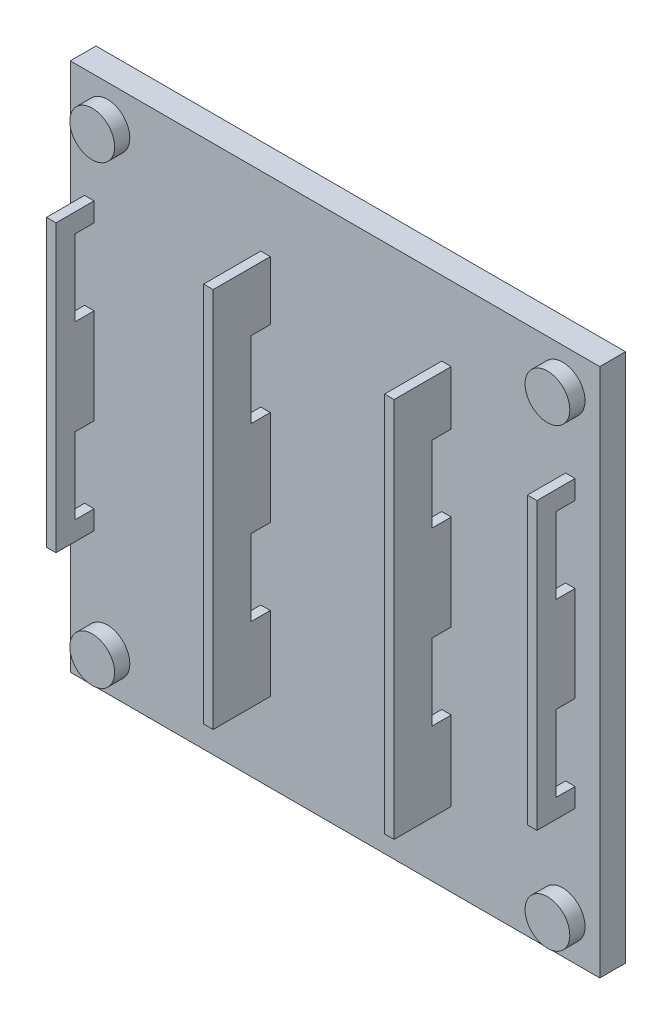
from build123d import *

# Parameters (mm, degrees)
SKICA1_W                 = 55.6
SKICA1_H                 = 55.6
SKICA1_R                 = 2.4
P_IDAT_VYSUNUT_M1_DEPTH  = 1.9
SKICA2_W                 = 55.6
SKICA2_H                 = 55.6
P_IDAT_VYSUNUT_M2_DEPTH  = 0.8
SKICA3_R                 = 2.35
P_IDAT_VYSUNUT_M3_DEPTH  = 1.6
SKICA12_W                = 1
SKICA12_H                = 40
P_IDAT_VYSUNUT_M5_DEPTH  = 6
SKICA13_W                = 1
SKICA13_H                = 30
P_IDAT_VYSUNUT_M6_DEPTH  = 4
SKICA14_W                = 2
SKICA14_H                = 8
ODEBRAT_VYSUNUT_M6_DEPTH = 54
SKICA17_W                = 5.5
SKICA17_H                = 42
SKICA17_W_2              = 42
SKICA17_H_2              = 5.5
ODEBRAT_VYSUNUT_M7_DEPTH = 1.9


with BuildPart() as part:
    # Skica1 → Přidat vysunutím1 (new body)
    with BuildSketch(Plane.XY):
        Rectangle(SKICA1_W, SKICA1_H)
        with Locations((-23.9, 23.9)):
            Circle(SKICA1_R, mode=Mode.SUBTRACT)
        with Locations((23.9, 23.9)):
            Circle(SKICA1_R, mode=Mode.SUBTRACT)
        with Locations((-23.9, -23.9)):
            Circle(SKICA1_R, mode=Mode.SUBTRACT)
        with Locations((23.9, -23.9)):
            Circle(SKICA1_R, mode=Mode.SUBTRACT)
    extrude(amount=P_IDAT_VYSUNUT_M1_DEPTH)

    # Skica2 → Přidat vysunutím2 (add)
    with BuildSketch(Plane.XY.offset(1.9)):
        Rectangle(SKICA2_W, SKICA2_H)
    extrude(amount=P_IDAT_VYSUNUT_M2_DEPTH)

    # Skica3 → Přidat vysunutím3 (add)
    with BuildSketch(Plane.XY.offset(2.7)):
        with Locations((-23.9, 23.9)):
            Circle(SKICA3_R)
        with Locations((23.9, 23.9)):
            Circle(SKICA3_R)
        with Locations((-23.9, -23.9)):
            Circle(SKICA3_R)
        with Locations((23.9, -23.9)):
            Circle(SKICA3_R)
    extrude(amount=P_IDAT_VYSUNUT_M3_DEPTH)

    # Skica12 → Přidat vysunutím5 (add)
    with BuildSketch(Plane.XY.offset(2.7)):
        with Locations((-7.3, 0.5)):
            Rectangle(SKICA12_W, SKICA12_H)
        with Locations((11.7, 0)):
            Rectangle(SKICA12_W, SKICA12_H)
    extrude(amount=P_IDAT_VYSUNUT_M5_DEPTH)

    # Skica13 → Přidat vysunutím6 (add)
    with BuildSketch(Plane.XY.offset(2.7)):
        with Locations((-25.8, 1.319838769)):
            Rectangle(SKICA13_W, SKICA13_H)
        with Locations((24.7, 1.319838769)):
            Rectangle(SKICA13_W, SKICA13_H)
    extrude(amount=P_IDAT_VYSUNUT_M6_DEPTH)

    # Skica14 → Odebrat vysunutím6 (cut)
    with BuildSketch(Plane.ZY.offset(26.3)):
        with Locations((3.7, 10.319838769)):
            Rectangle(SKICA14_W, SKICA14_H)
        with Locations((3.7, -7.680161231)):
            Rectangle(SKICA14_W, SKICA14_H)
    extrude(amount=-ODEBRAT_VYSUNUT_M6_DEPTH, mode=Mode.SUBTRACT)

    # Skica17 → Odebrat vysunutím7 (cut)
    with BuildSketch(Plane(origin=(0, 0, 0), x_dir=(-1, 0, 0), z_dir=(0, 0, -1))):
        with Locations((-23.75, 0)):
            Rectangle(SKICA17_W, SKICA17_H)
        with Locations((0, 23.75)):
            Rectangle(SKICA17_W_2, SKICA17_H_2)
        Rectangle(SKICA17_W_2, SKICA17_H)
        with Locations((23.75, 0)):
            Rectangle(SKICA17_W, SKICA17_H)
        with Locations((0, -23.75)):
            Rectangle(SKICA17_W_2, SKICA17_H_2)
    extrude(amount=-ODEBRAT_VYSUNUT_M7_DEPTH, mode=Mode.SUBTRACT)


solid = part.part
